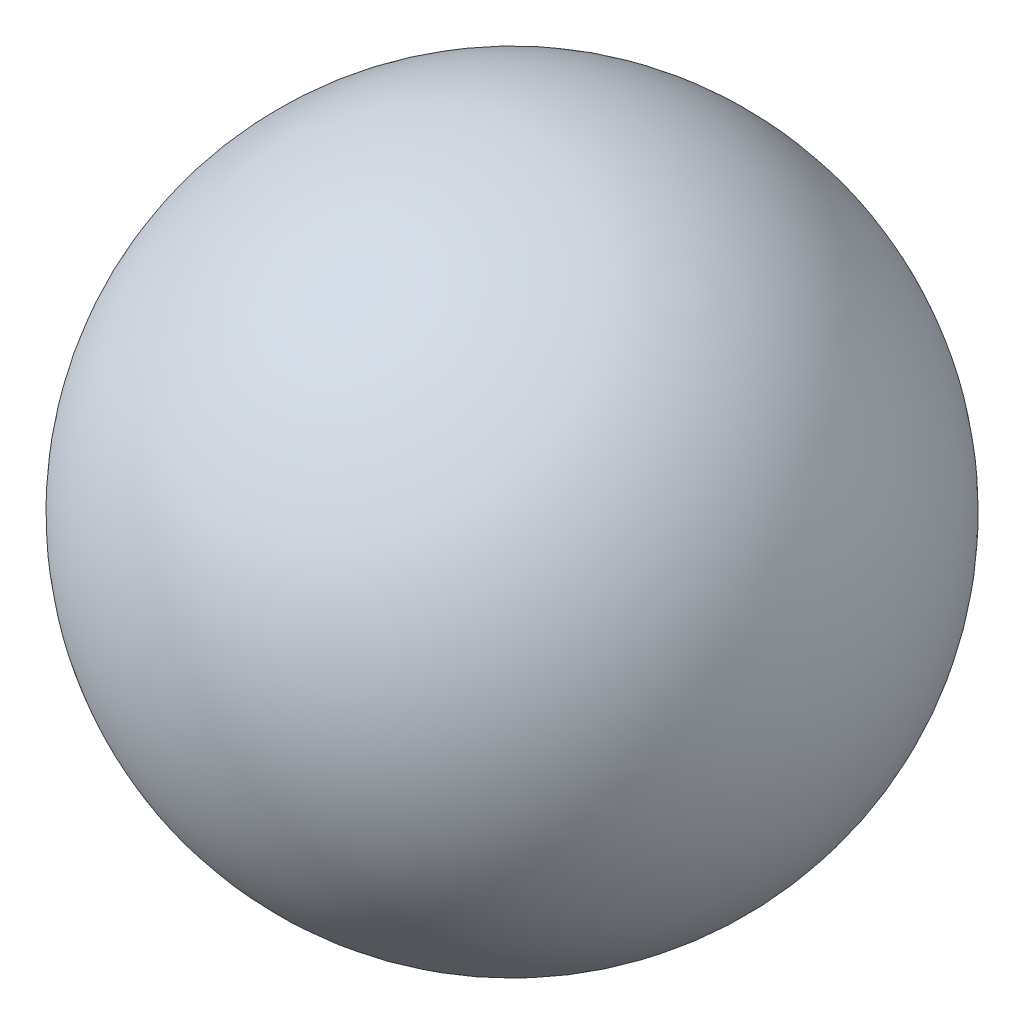
from build123d import *


with BuildPart() as part:
    # Sketch2 → Revolve2 (revolve)
    with BuildSketch(Plane(origin=(0, 0, 0), x_dir=(1, 0, 0), z_dir=(0, 1, 0))):
        with BuildLine():
            Line((0, 0), (0, 60))
            ThreePointArc((0, 60), (-30, 30), (0, 0))
        make_face()
    revolve(axis=Axis((0, 0, 0), (0, 0, -1)))


solid = part.part
